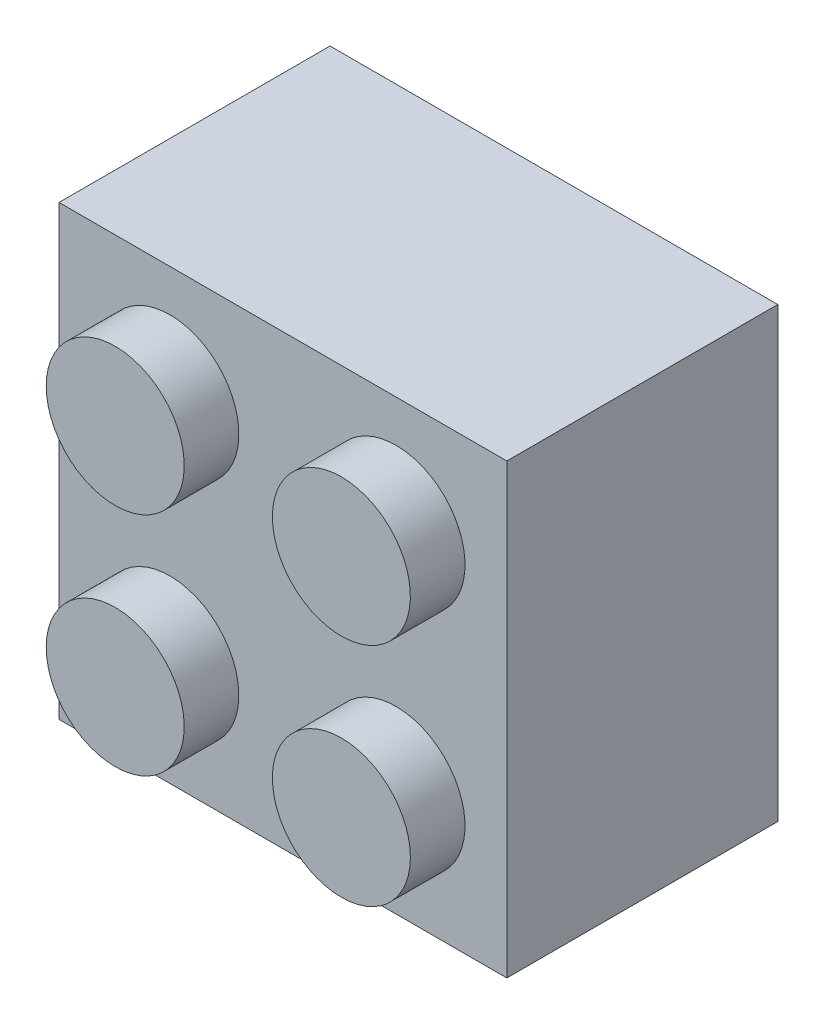
from build123d import *

# Parameters (mm, degrees)
SKETCH1_W           = 15.8242
SKETCH1_H           = 15.8242
BOSS_EXTRUDE1_DEPTH = 9.5758
SKETCH2_W           = 13.4366
SKETCH2_H           = 13.4366
SKETCH2_R           = 3.2131
CUT_EXTRUDE1_DEPTH  = 8.4328
SKETCH3_R           = 2.4384
CUT_EXTRUDE2_DEPTH  = 8.4328
SKETCH4_R           = 2.4384
BOSS_EXTRUDE2_DEPTH = 1.9304
CIRPATTERN1_COUNT   = 4


with BuildPart() as part:
    # Sketch1 → Boss-Extrude1 (new body)
    with BuildSketch(Plane.XY):
        Rectangle(SKETCH1_W, SKETCH1_H)
    extrude(amount=BOSS_EXTRUDE1_DEPTH)

    # Sketch2 → Cut-Extrude1 (cut)
    with BuildSketch(Plane(origin=(0, 0, 0), x_dir=(-1, 0, 0), z_dir=(0, 0, -1))):
        Rectangle(SKETCH2_W, SKETCH2_H)
        Circle(SKETCH2_R, mode=Mode.SUBTRACT)
    extrude(amount=-CUT_EXTRUDE1_DEPTH, mode=Mode.SUBTRACT)

    # Sketch3 → Cut-Extrude2 (cut)
    with BuildSketch(Plane(origin=(0, 0, 0), x_dir=(-1, 0, 0), z_dir=(0, 0, -1))):
        Circle(SKETCH3_R)
    extrude(amount=-CUT_EXTRUDE2_DEPTH, mode=Mode.SUBTRACT)

    # Sketch4 → Boss-Extrude2 (add)
    with BuildSketch(Plane.XY.offset(9.5758)):
        with Locations((3.996213974, -3.996213974)):
            Circle(SKETCH4_R)
    boss_extrude2 = extrude(amount=BOSS_EXTRUDE2_DEPTH)

    # CirPattern1: Boss-Extrude2 ×4 about axis
    cirpattern1_axis = Axis((0, 0, 0), (0, 0, 1))
    for i in range(1, CIRPATTERN1_COUNT):
        add(boss_extrude2.rotate(cirpattern1_axis, i * 360 / CIRPATTERN1_COUNT))


solid = part.part
